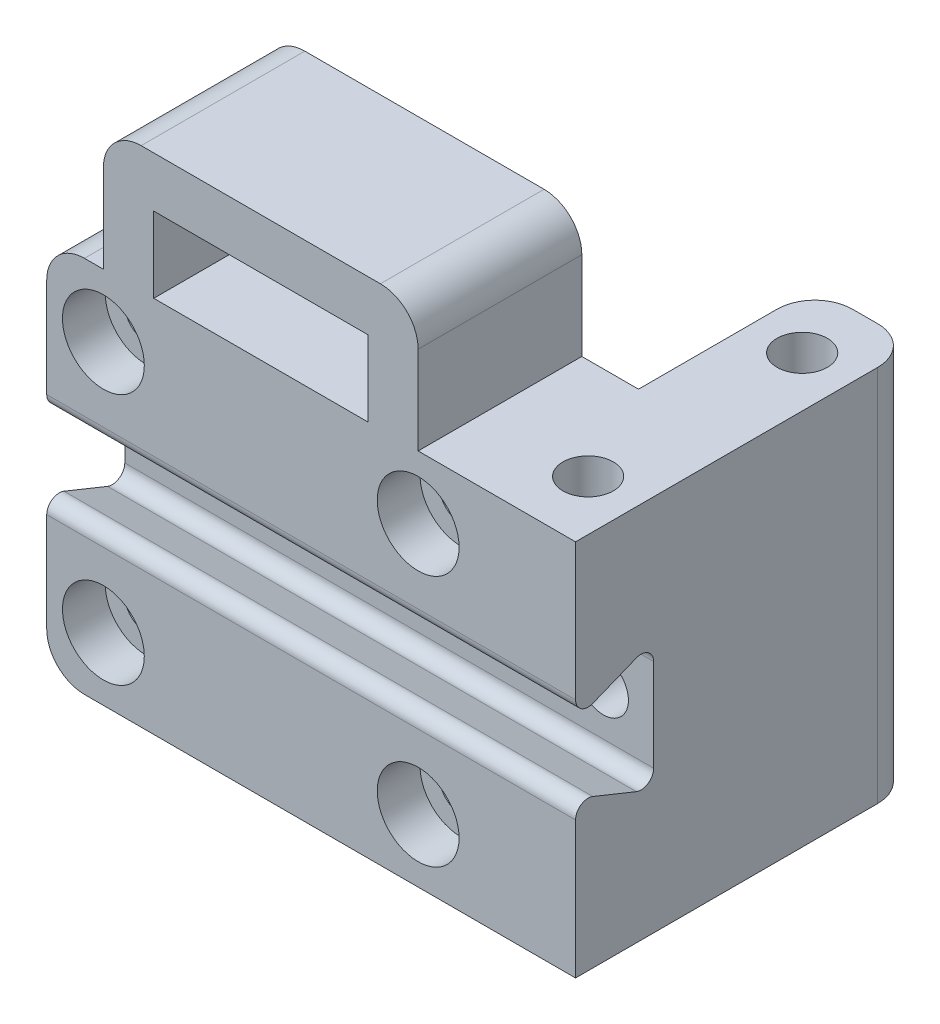
from build123d import *

# Parameters (mm, degrees)
SKIZZE1_W                                            = 34
SKIZZE1_H                                            = 30
AUFSATZ_LINEAR_AUSTRAGEN1_DEPTH                      = 13
STIRNSENKUNG_F_R_M3_ZYLINDERSCHRAUBE_MIT_D           = 3.4
STIRNSENKUNG_F_R_M3_ZYLINDERSCHRAUBE_MIT_CBORE_D     = 6.5
STIRNSENKUNG_F_R_M3_ZYLINDERSCHRAUBE_MIT_CBORE_DEPTH = 3.4
SKIZZE4_W                                            = 8
SKIZZE4_H                                            = 27
AUFSATZ_LINEAR_AUSTRAGEN2_DEPTH                      = 30
F_4_0_4_DURCHMESSER_BOHRUNG1_AT_2_COUNT              = 2
F_4_0_4_DURCHMESSER_BOHRUNG1_AT_2_PITCH              = 17
SCHNITT_LINEAR_AUSTRAGEN1_DEPTH                      = 43
AUFSATZ_LINEAR_AUSTRAGEN3_DEPTH                      = 13
VERRUNDUNG2_R                                        = 3
VERRUNDUNG1_R                                        = 3
VERRUNDUNG4_R                                        = 1
F_4_0_4_DURCHMESSER_BOHRUNG2_D                       = 4
F_4_0_4_DURCHMESSER_BOHRUNG2_DEPTH                   = 5
F_4_0_4_DURCHMESSER_BOHRUNG2_TIP                     = 1.201721238


with BuildPart() as part:
    # Skizze1 → Aufsatz-Linear austragen1 (new body)
    with BuildSketch(Plane.XY):
        Rectangle(SKIZZE1_W, SKIZZE1_H)
    extrude(amount=AUFSATZ_LINEAR_AUSTRAGEN1_DEPTH)

    # Stirnsenkung für M3 Zylinderschraube mit Innensechskant1 (through all)
    with Locations(Plane.XY.offset(13)):
        with Locations((-12.5, 10), (-12.5, -10), (12.5, -10), (12.5, 10)):
            CounterBoreHole(STIRNSENKUNG_F_R_M3_ZYLINDERSCHRAUBE_MIT_D / 2, STIRNSENKUNG_F_R_M3_ZYLINDERSCHRAUBE_MIT_CBORE_D / 2, STIRNSENKUNG_F_R_M3_ZYLINDERSCHRAUBE_MIT_CBORE_DEPTH)

    # Skizze4 → Aufsatz-Linear austragen2 (add, through all)
    with BuildSketch(Plane(origin=(0, 15, 0), x_dir=(1, 0, 0), z_dir=(0, 1, 0))):
        with Locations((21, 0.5)):
            Rectangle(SKIZZE4_W, SKIZZE4_H)
    extrude(amount=-AUFSATZ_LINEAR_AUSTRAGEN2_DEPTH)

    # Skizze6 → Ø4.0 (4) Durchmesser Bohrung1 (revolve, cut)
    with BuildSketch(Plane(origin=(21, 15, 8), x_dir=(0, 0, 1), z_dir=(1, 0, 0))):
        Polygon((0, 0), (0, 6.201721238), (2, 5), (2, 0), align=None)
    f_4_0_4_durchmesser_bohrung1 = revolve(axis=Axis((21, 21.35, 8), (0, -1, 0)), mode=Mode.SUBTRACT)

    # Ø4.0 (4) Durchmesser Bohrung1 at 2: Ø4.0 (4) Durchmesser Bohrung1 ×2
    with Locations(*[(0, 0, -i * F_4_0_4_DURCHMESSER_BOHRUNG1_AT_2_PITCH) for i in range(1, F_4_0_4_DURCHMESSER_BOHRUNG1_AT_2_COUNT)]):
        add(f_4_0_4_durchmesser_bohrung1, mode=Mode.SUBTRACT)

    # Spiegeln1: Ø4.0 (4) Durchmesser Bohrung1 across plane
    add(f_4_0_4_durchmesser_bohrung1.mirror(Plane.ZX), mode=Mode.SUBTRACT)

    # Spiegeln1 copy 1 sketch → Spiegeln1 copy 1 (revolve, cut)
    with BuildSketch(Plane(origin=(21, -15, -9), x_dir=(0, 0, 1), z_dir=(1, 0, 0))):
        Polygon((0, 0), (0, -6.201721238), (2, -5), (2, 0), align=None)
    revolve(axis=Axis((21, -21.35, -9), (0, -1, 0)), mode=Mode.SUBTRACT)

    # Skizze7 → Schnitt-Linear austragen1 (cut, through all)
    with BuildSketch(Plane.ZY.offset(17)):
        Polygon((13, 2.65), (6.8, 5.15), (6.8, -5.15), (13, -2.65), align=None)
    extrude(amount=-SCHNITT_LINEAR_AUSTRAGEN1_DEPTH, mode=Mode.SUBTRACT)

    # Skizze10 → Aufsatz-Linear austragen3 (add)
    with BuildSketch(Plane(origin=(0, 0, 0), x_dir=(-1, 0, 0), z_dir=(0, 0, -1))):
        Polygon((-12.5, 15), (-8.5, 15), (-8.5, 21), (8.5, 21), (8.5, 15), (12.5, 15), (12.5, 25), (-12.5, 25), align=None)
    extrude(amount=-AUFSATZ_LINEAR_AUSTRAGEN3_DEPTH)

    # Verrundung2
    verrundung2_edges = [part.edges().sort_by_distance(p)[0] for p in [
        (-17, 15, 6.5),
        (-17, -15, 6.5),
        (-12.5, 25, 6.5),
        (12.5, 25, 6.5),
    ]]
    fillet(verrundung2_edges, radius=VERRUNDUNG2_R)

    # Verrundung1
    verrundung1_edges = [part.edges().sort_by_distance(p)[0] for p in [
        (17, 0, -14),
        (25, 0, -14),
    ]]
    fillet(verrundung1_edges, radius=VERRUNDUNG1_R)

    # Verrundung4
    verrundung4_edges = [part.edges().sort_by_distance(p)[0] for p in [
        (4, 2.65, 13),
        (4, -2.65, 13),
        (4, -5.15, 6.8),
        (4, 5.15, 6.8),
    ]]
    fillet(verrundung4_edges, radius=VERRUNDUNG4_R)

    # Ø4.0 (4) Durchmesser Bohrung2
    with Locations(Plane.XY.offset(6.8)):
        with Locations((21, 0)):
            Hole(F_4_0_4_DURCHMESSER_BOHRUNG2_D / 2, depth=F_4_0_4_DURCHMESSER_BOHRUNG2_DEPTH)
            with Locations((0, 0, -(F_4_0_4_DURCHMESSER_BOHRUNG2_DEPTH + F_4_0_4_DURCHMESSER_BOHRUNG2_TIP / 2))):  # 118° drill point
                Cone(0, F_4_0_4_DURCHMESSER_BOHRUNG2_D / 2, F_4_0_4_DURCHMESSER_BOHRUNG2_TIP, mode=Mode.SUBTRACT)


solid = part.part
